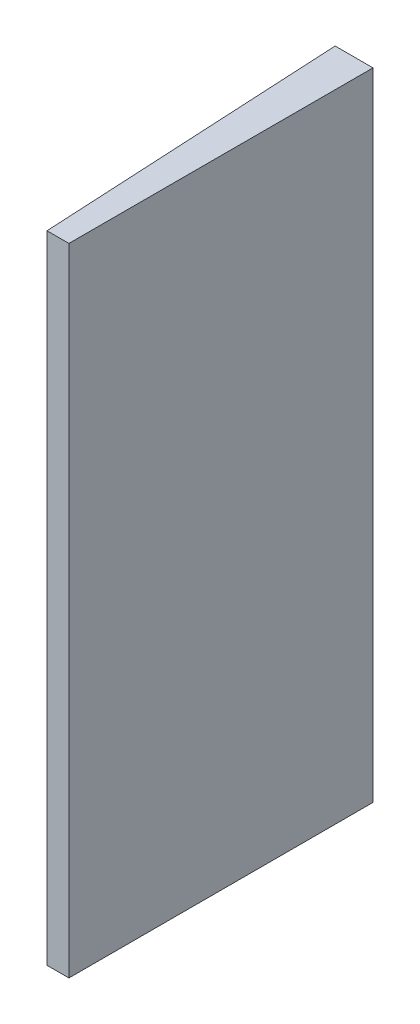
from build123d import *

# Parameters (mm, degrees)
BOSS_EXTRUDE1_DEPTH = 42
SKETCH2_R           = 3.3
BOSS_EXTRUDE2_DEPTH = 1.8


with BuildPart() as part:
    # Sketch1 → Boss-Extrude1 (new body, symmetric)
    with BuildSketch(Plane(origin=(0, 0, 0), x_dir=(1, 0, 0), z_dir=(0, 1, 0))):
        Polygon((0, 20.075), (0, -20.075), (-2.895827662, -20.075), (-5, 20.075), align=None)
    extrude(amount=BOSS_EXTRUDE1_DEPTH, both=True)

    # Sketch2 → Boss-Extrude2 (add)
    with BuildSketch(Plane(origin=(-3.937100288, 0, 0.206334683), x_dir=(0.052335956, 0, 0.998629535), z_dir=(-0.998629535, 0, 0.052335956))):
        with Locations((-5.109167691, -29.895651858)):
            Circle(SKETCH2_R)
        with Locations((-5.109167691, 29.895651858)):
            Circle(SKETCH2_R)
    extrude(amount=BOSS_EXTRUDE2_DEPTH)


solid = part.part
